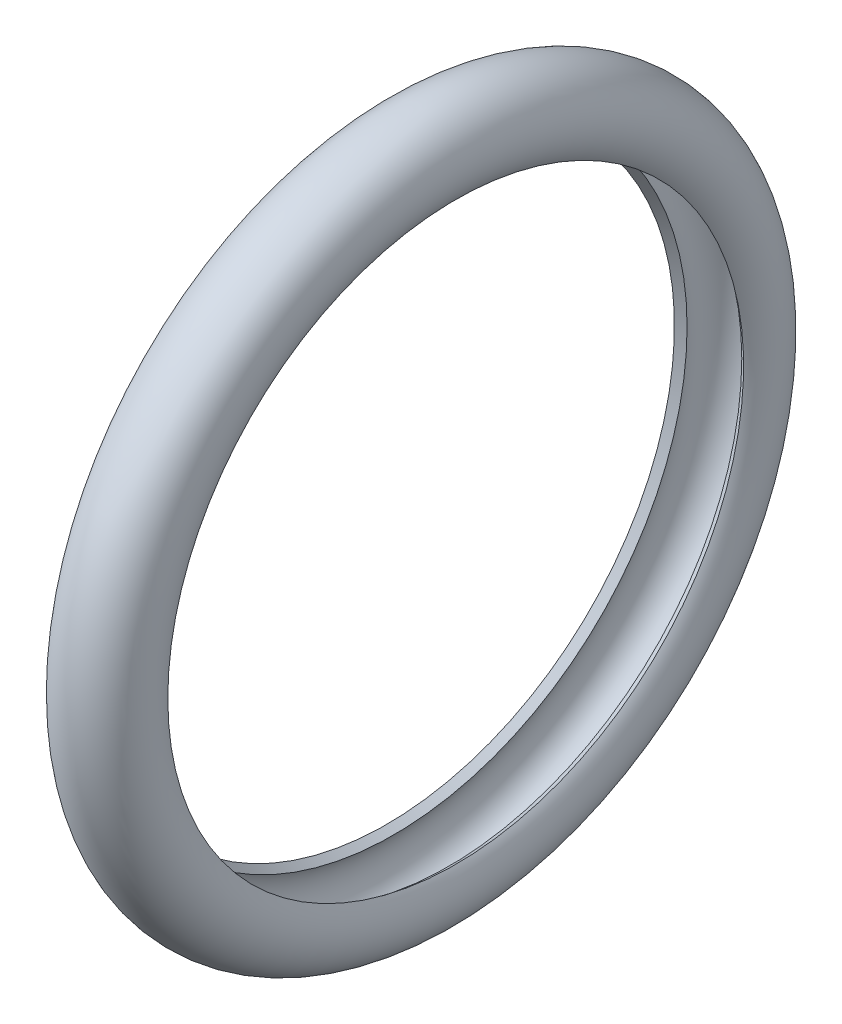
from build123d import *


with BuildPart() as part:
    # Sketch1 → Revolve1 (revolve)
    with BuildSketch(Plane.XY):
        with BuildLine():
            Line((1.129726799, 7.97), (1.330039924, 8.11958159))
            ThreePointArc((1.330039924, 8.11958159), (2.087223536, 9.63), (2.844407147, 8.11958159))
            Line((2.844407147, 8.11958159), (3.044720272, 7.97))
            ThreePointArc((3.044720272, 7.97), (2.087223536, 9.88), (1.129726799, 7.97))
        make_face()
    revolve(axis=Axis((-88.99, 0, 0), (1, 0, 0)))


solid = part.part
